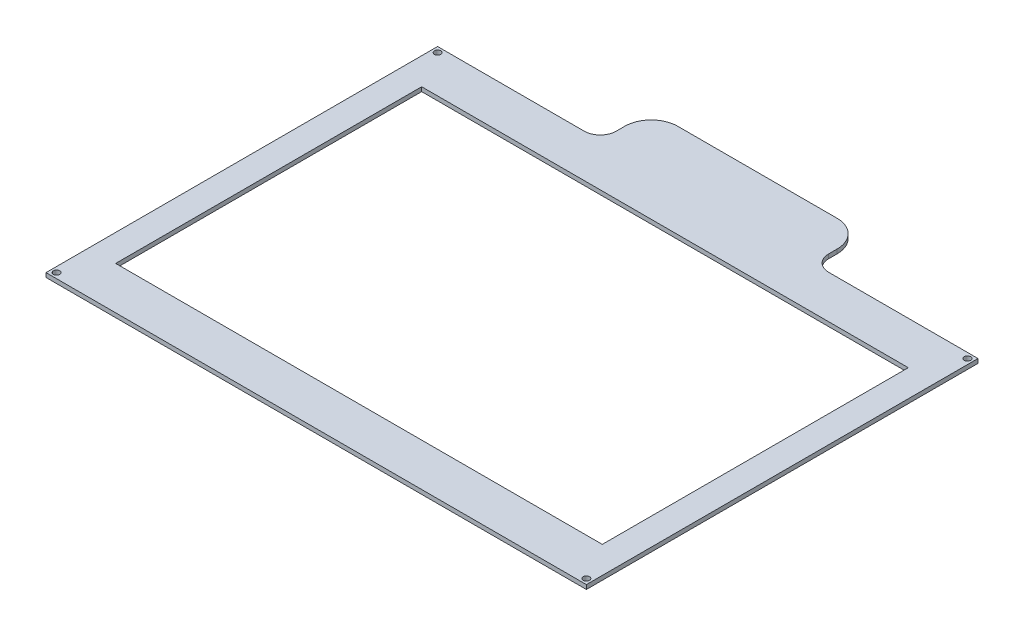
from build123d import *

# Parameters (mm, degrees)
SKETCH3_R           = 1.5
SKETCH3_W           = 229
SKETCH3_H           = 144
BOSS_EXTRUDE2_DEPTH = 2


with BuildPart() as part:
    # Sketch3 → Boss-Extrude2 (new body)
    with BuildSketch(Plane(origin=(0, 0, 0), x_dir=(1, 0, 0), z_dir=(0, 1, 0))):
        with BuildLine():
            Line((-127.15, 80.141387187), (-58.12279793, 80.141387187))
            ThreePointArc((-58.12279793, 80.141387187), (-52.819497071, 82.338086328), (-50.62279793, 87.641387187))
            Line((-50.62279793, 87.641387187), (-50.62279793, 91.641387187))
            ThreePointArc((-50.62279793, 91.641387187), (-46.961632695, 100.480221952), (-38.12279793, 104.141387187))
            Line((-38.12279793, 104.141387187), (36.87720207, 104.141387187))
            ThreePointArc((36.87720207, 104.141387187), (45.716036835, 100.480221952), (49.37720207, 91.641387187))
            Line((49.37720207, 91.641387187), (49.37720207, 87.641387187))
            ThreePointArc((49.37720207, 87.641387187), (51.573901211, 82.338086328), (56.87720207, 80.141387187))
            Line((56.87720207, 80.141387187), (127.15, 80.141387187))
            Line((127.15, 80.141387187), (127.15, -104.141387187))
            Line((127.15, -104.141387187), (-127.15, -104.141387187))
            Line((-127.15, -104.141387187), (-127.15, 80.141387187))
        make_face()
        with Locations((-124.667766953, 77.65915414)):
            Circle(SKETCH3_R, mode=Mode.SUBTRACT)
        with Locations((124.667766953, 77.65915414)):
            Circle(SKETCH3_R, mode=Mode.SUBTRACT)
        with Locations((124.667766953, -101.667766953)):
            Circle(SKETCH3_R, mode=Mode.SUBTRACT)
        with Locations((-124.667766953, -101.667766953)):
            Circle(SKETCH3_R, mode=Mode.SUBTRACT)
        with Locations((0, -12.008612813)):
            Rectangle(SKETCH3_W, SKETCH3_H, mode=Mode.SUBTRACT)
    extrude(amount=BOSS_EXTRUDE2_DEPTH)


solid = part.part
